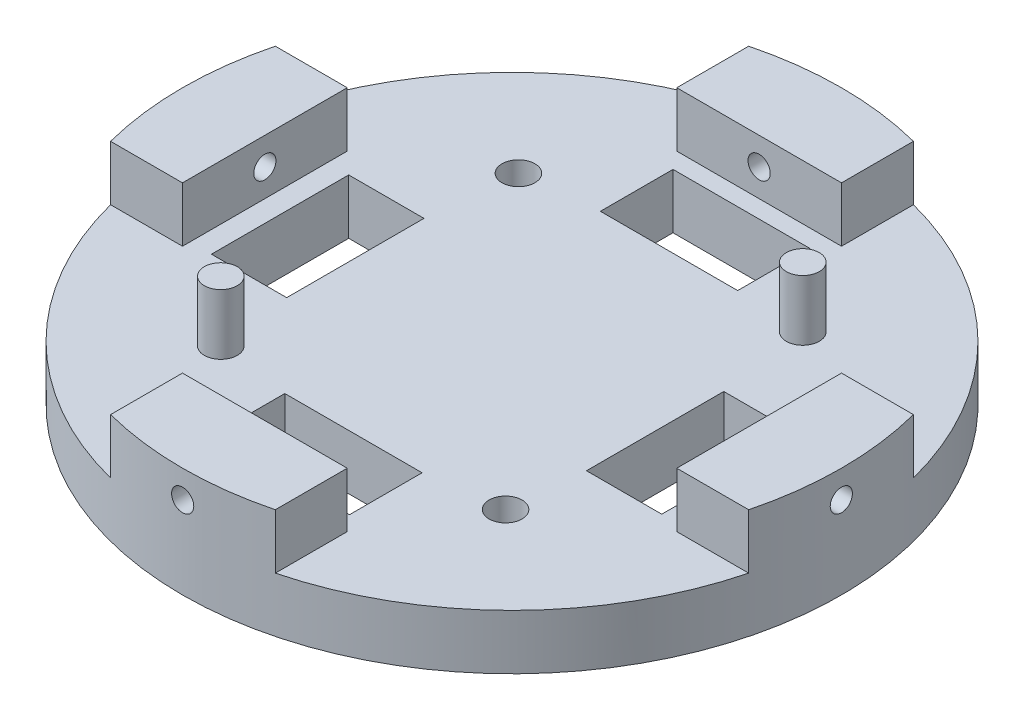
from build123d import *
from build123d.topology import SkipClean

# Parameters (mm, degrees)
SKETCH1_R           = 76.2
BOSS_EXTRUDE1_DEPTH = 12.7
SKETCH9_W           = 17.40446846
SKETCH9_H           = 31.75
SKETCH9_W_2         = 17.404468459
SKETCH9_W_3         = 31.75
SKETCH9_H_2         = 16.793136505
CUT_EXTRUDE1_DEPTH  = 12.7
SKETCH12_R          = 3.81
CUT_EXTRUDE7_DEPTH  = 109.508847566
SKETCH14_R          = 3.81
BOSS_EXTRUDE5_DEPTH = 13.97
BOSS_EXTRUDE6_DEPTH = 12.7
SKETCH15_R          = 2.5654
CUT_EXTRUDE8_DEPTH  = 156.884416797
CIRPATTERN1_COUNT   = 4


with BuildPart() as part:
    # Sketch1 → Boss-Extrude1 (new body)
    with BuildSketch(Plane(origin=(0, 0, 0), x_dir=(1, 0, 0), z_dir=(0, 1, 0))):
        Circle(SKETCH1_R)
    extrude(amount=BOSS_EXTRUDE1_DEPTH)

    # Sketch9 → Cut-Extrude1 (cut)
    with BuildSketch(Plane(origin=(0, 12.7, 0), x_dir=(1, 0, 0), z_dir=(0, 1, 0))):
        with Locations((43.222256972, -1.420690531)):
            Rectangle(SKETCH9_W, SKETCH9_H)
        with Locations((-43.511171149, -1.420690531)):
            Rectangle(SKETCH9_W_2, SKETCH9_H)
        with Locations((0.046278064, 44.665088999)):
            Rectangle(SKETCH9_W_3, SKETCH9_H_2)
        with Locations((0.046278064, -45.105910611)):
            Rectangle(SKETCH9_W_3, SKETCH9_H_2)
    extrude(amount=-CUT_EXTRUDE1_DEPTH, mode=Mode.SUBTRACT)

    # Sketch12 → Cut-Extrude7 (cut, through all)
    with BuildSketch(Plane(origin=(0, 12.7, 0), x_dir=(1, 0, 0), z_dir=(0, 1, 0))):
        with Locations((-32.923159658, 34.412296975)):
            Circle(SKETCH12_R)
        with Locations((32.923159658, -34.412296975)):
            Circle(SKETCH12_R)
    extrude(amount=-CUT_EXTRUDE7_DEPTH, mode=Mode.SUBTRACT)

    # Sketch14 → Boss-Extrude5 (add)
    with BuildSketch(Plane(origin=(0, 12.7, 0), x_dir=(1, 0, 0), z_dir=(0, 1, 0))):
        with Locations((31.714292366, 35.529484723)):
            Circle(SKETCH14_R)
        with Locations((-32.761256964, -34.580899947)):
            Circle(SKETCH14_R)
    extrude(amount=BOSS_EXTRUDE5_DEPTH)

    # Sketch2 → Boss-Extrude6 (add)
    with BuildSketch(Plane(origin=(0, 12.7, 0), x_dir=(1, 0, 0), z_dir=(0, 1, 0))):
        with BuildLine():
            Line((-19.05, -73.780332745), (-19.05, -57.15))
            Line((-19.05, -57.15), (19.05, -57.15))
            Line((19.05, -57.15), (19.05, -73.780332745))
            ThreePointArc((19.05, -73.780332745), (0, -76.2), (-19.05, -73.780332745))
        make_face()
    boss_extrude6 = extrude(amount=BOSS_EXTRUDE6_DEPTH)

    # Sketch15 → Cut-Extrude8 (cut, through all)
    with BuildSketch(Plane(origin=(0, 0, 57.15), x_dir=(-1, 0, 0), z_dir=(0, 0, -1))):
        with Locations((0, 19.05)):
            Circle(SKETCH15_R)
    cut_extrude8 = extrude(amount=-CUT_EXTRUDE8_DEPTH, mode=Mode.SUBTRACT)

    # CirPattern1: Boss-Extrude6, Cut-Extrude8 ×4 about axis
    with SkipClean():  # the faces are left unmerged after this step: merging them gives an invalid solid
        cirpattern1_axis = Axis((0, 28.0035, 0), (0, -1, 0))
        add([boss_extrude6.rotate(cirpattern1_axis, i * 360 / CIRPATTERN1_COUNT) for i in range(1, CIRPATTERN1_COUNT)])
        add([cut_extrude8.rotate(cirpattern1_axis, i * 360 / CIRPATTERN1_COUNT) for i in range(1, CIRPATTERN1_COUNT)], mode=Mode.SUBTRACT)


solid = part.part
